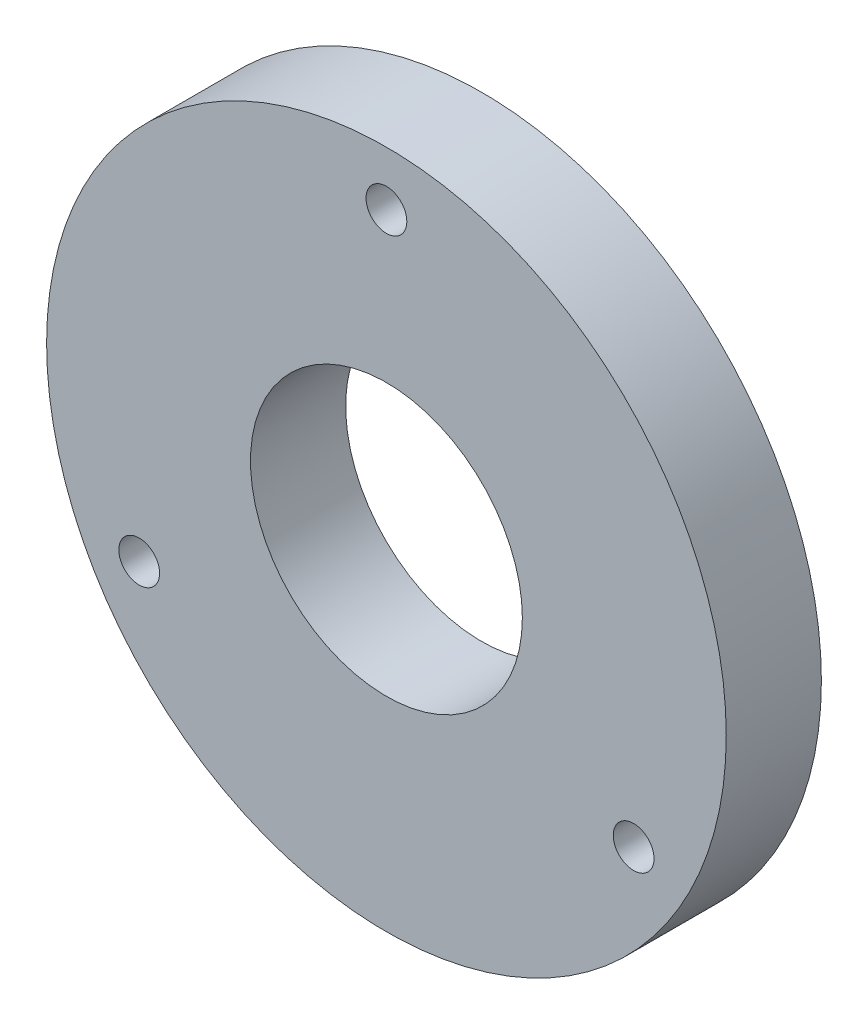
from build123d import *

# Parameters (mm, degrees)
SKETCH1_R             = 25
SKETCH1_R_2           = 10
BOSS_EXTRUDE2_DEPTH   = 7
F_3_0MM_DOWEL_HOLE1_D = 3
CIRPATTERN1_COUNT     = 3


with BuildPart() as part:
    # Sketch1 → Boss-Extrude2 (new body)
    with BuildSketch(Plane.XY):
        Circle(SKETCH1_R)
        Circle(SKETCH1_R_2, mode=Mode.SUBTRACT)
    extrude(amount=BOSS_EXTRUDE2_DEPTH)

    # Ø3.0mm Dowel Hole1 (through all)
    with Locations(Plane.XY.offset(7)):
        with Locations((0, 21)):
            f_3_0mm_dowel_hole1 = Hole(F_3_0MM_DOWEL_HOLE1_D / 2)

    # CirPattern1: Ø3.0mm Dowel Hole1 ×3 about axis
    cirpattern1_axis = Axis((0, 0, 0), (0, 0, 1))
    for i in range(1, CIRPATTERN1_COUNT):
        add(f_3_0mm_dowel_hole1.rotate(cirpattern1_axis, i * 360 / CIRPATTERN1_COUNT), mode=Mode.SUBTRACT)


solid = part.part
